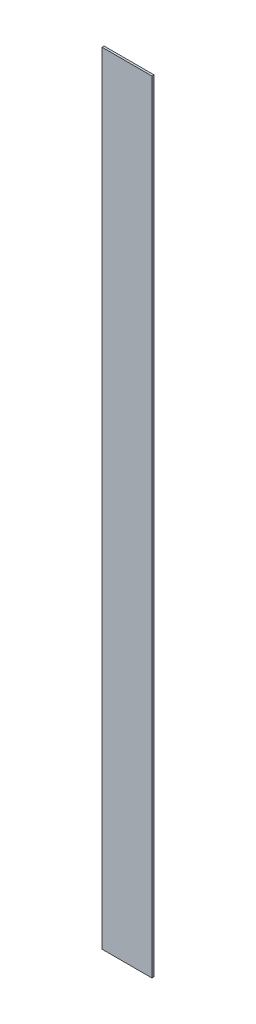
from build123d import *

# Parameters (mm, degrees)
SKETCH1_W           = 96
SKETCH1_H           = 1504
BOSS_EXTRUDE1_DEPTH = 4


with BuildPart() as part:
    # Sketch1 → Boss-Extrude1 (new body)
    with BuildSketch(Plane.XY):
        with Locations((-11.252592981, 663.460712415)):
            Rectangle(SKETCH1_W, SKETCH1_H)
    extrude(amount=BOSS_EXTRUDE1_DEPTH)


solid = part.part
